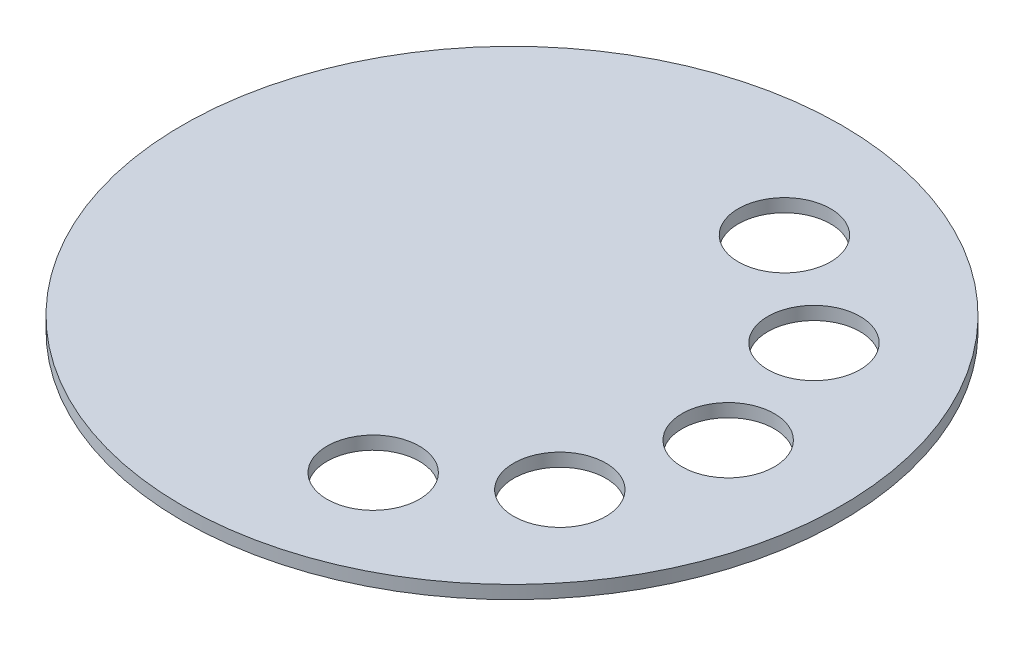
from build123d import *

# Parameters (mm, degrees)
SKETCH1_R           = 125
BOSS_EXTRUDE1_DEPTH = 5
SKETCH1_5_R         = 17.5
CUT_EXTRUDE4_DEPTH  = 10


with BuildPart() as part:
    # Sketch1 → Boss-Extrude1 (new body)
    with BuildSketch(Plane(origin=(0, 0, 0), x_dir=(1, 0, 0), z_dir=(0, 1, 0))):
        Circle(SKETCH1_R)
    extrude(amount=BOSS_EXTRUDE1_DEPTH)

    # Sketch1_5 → Cut-Extrude4 (cut)
    with BuildSketch(Plane(origin=(0, 0, 0), x_dir=(1, 0, 0), z_dir=(0, 1, 0))):
        with Locations((25.339393539, 77.986634336)):
            Circle(SKETCH1_5_R)
        with Locations((66.339393539, 48.198390688)):
            Circle(SKETCH1_5_R)
        with Locations((82, 0)):
            Circle(SKETCH1_5_R)
        with Locations((66.339393539, -48.198390688)):
            Circle(SKETCH1_5_R)
        with Locations((25.339393539, -77.986634336)):
            Circle(SKETCH1_5_R)
    extrude(amount=CUT_EXTRUDE4_DEPTH, mode=Mode.SUBTRACT)


solid = part.part
